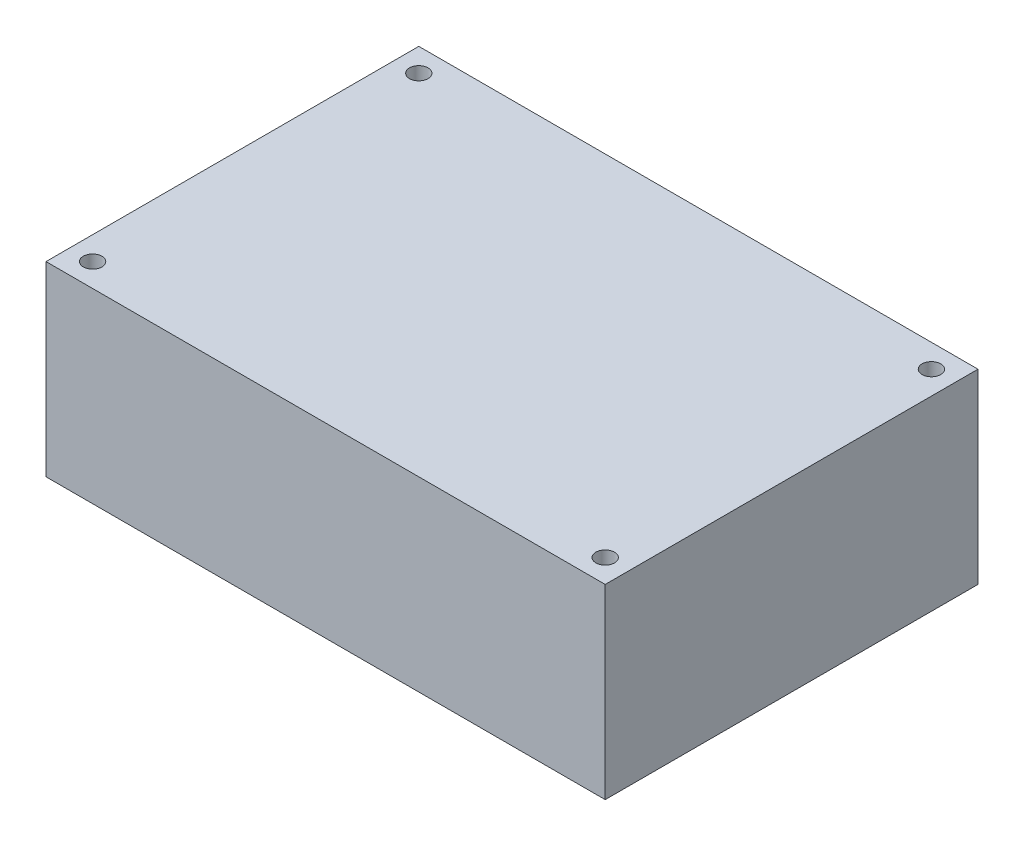
from build123d import *

# Parameters (mm, degrees)
SKETCH1_W           = 60
SKETCH1_H           = 40
SKETCH1_R           = 1
BOSS_EXTRUDE1_DEPTH = 20


with BuildPart() as part:
    # Sketch1 → Boss-Extrude1 (new body)
    with BuildSketch(Plane(origin=(0, 0, 0), x_dir=(1, 0, 0), z_dir=(0, 1, 0))):
        Rectangle(SKETCH1_W, SKETCH1_H)
        with Locations((-27.5, 17.5)):
            Circle(SKETCH1_R, mode=Mode.SUBTRACT)
        with Locations((27.5, 17.5)):
            Circle(SKETCH1_R, mode=Mode.SUBTRACT)
        with Locations((27.5, -17.5)):
            Circle(SKETCH1_R, mode=Mode.SUBTRACT)
        with Locations((-27.5, -17.5)):
            Circle(SKETCH1_R, mode=Mode.SUBTRACT)
    extrude(amount=BOSS_EXTRUDE1_DEPTH)


solid = part.part
